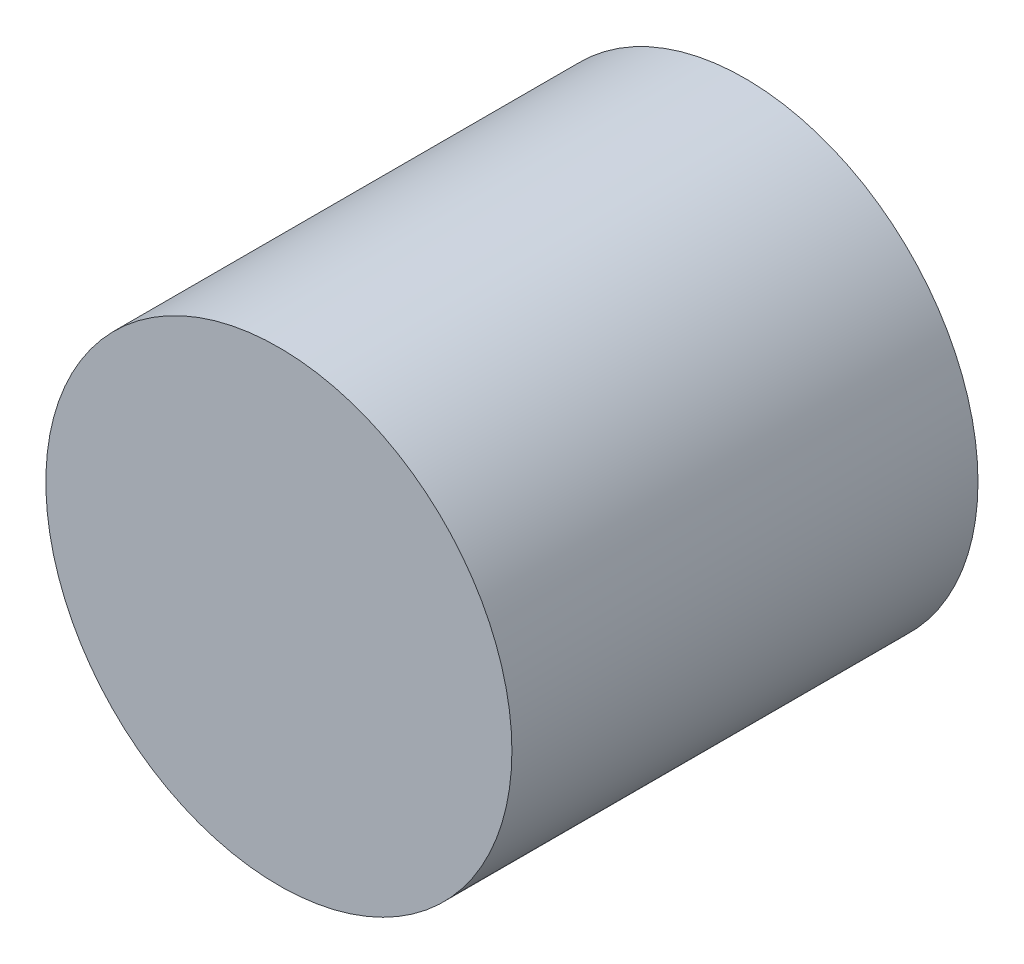
from build123d import *

# Parameters (mm, degrees)
SKETCH1_R           = 2
BOSS_EXTRUDE1_DEPTH = 4


with BuildPart() as part:
    # Sketch1 → Boss-Extrude1 (new body)
    with BuildSketch(Plane.XY):
        Circle(SKETCH1_R)
    extrude(amount=BOSS_EXTRUDE1_DEPTH)


solid = part.part
